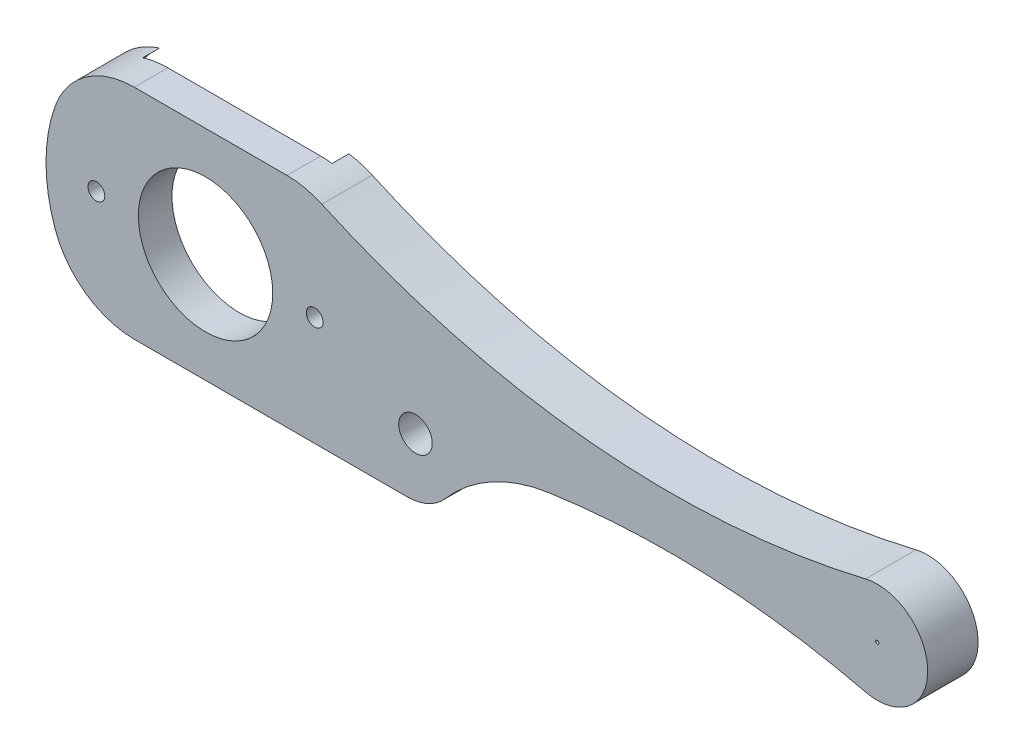
from build123d import *

# Parameters (mm, degrees)
SKIZZE1_W                       = 70
SKIZZE1_H                       = 30
SKIZZE1_R                       = 4
SKIZZE1_R_2                     = 0.1
LINEAR_AUSTRAGEN1_DEPTH         = 3
F_1_0_1_DIAMETER_HOLE1_D        = 1
F_2_0_2_DIAMETER_HOLE1_D        = 2
SKIZZE7_R                       = 8.5
SCHNITT_LINEAR_AUSTRAGEN1_DEPTH = 1
SKIZZE8_OUTSIDE_W               = 87.244
SKIZZE8_OUTSIDE_H               = 47.244
SCHNITT_LINEAR_AUSTRAGEN2_DEPTH = 58.087651905
SCHNITT_LINEAR_AUSTRAGEN3_DEPTH = 1.2


with BuildPart() as part:
    # Skizze1 → Linear austragen1 (new body)
    with BuildSketch(Plane.XY):
        with Locations((20, 0)):
            Rectangle(SKIZZE1_W, SKIZZE1_H)
        Circle(SKIZZE1_R, mode=Mode.SUBTRACT)
        with Locations((40, 0)):
            Circle(SKIZZE1_R_2, mode=Mode.SUBTRACT)
    extrude(amount=LINEAR_AUSTRAGEN1_DEPTH)

    # Ø1.0 (1) Diameter Hole1 (through all)
    with Locations(Plane(origin=(0, 0, 0), x_dir=(-1, 0, 0), z_dir=(0, 0, -1))):
        with Locations((6.5, 0), (-6.5, 0)):
            Hole(F_1_0_1_DIAMETER_HOLE1_D / 2)

    # Ø2.0 (2) Diameter Hole1 (through all)
    with Locations(Plane(origin=(0, 0, 0), x_dir=(1, 0, 0), z_dir=(0, 0, -1))):
        with Locations((12.5, 3)):
            Hole(F_2_0_2_DIAMETER_HOLE1_D / 2)

    # Skizze7 → Schnitt-Linear austragen1 (cut)
    with BuildSketch(Plane.XY):
        Circle(SKIZZE7_R)
    extrude(amount=SCHNITT_LINEAR_AUSTRAGEN1_DEPTH, mode=Mode.SUBTRACT)

    # Skizze8 outside → Schnitt-Linear austragen2 (cut, through all)
    with BuildSketch(Plane.XY):
        with Locations((20, 0)):
            Rectangle(SKIZZE8_OUTSIDE_W, SKIZZE8_OUTSIDE_H)
        with BuildLine():
            Line((-4.242640687, 6.5), (4.850693198, 6.5))
            ThreePointArc((4.850693198, 6.5), (5.911913676, 6.386083411), (6.924777907, 6.049524439))
            ThreePointArc((6.924777907, 6.049524439), (22.851496839, 1.777066749), (39.30182783, 2.917628424))
            ThreePointArc((39.30182783, 2.917628424), (43, 0), (39.30182783, -2.917628424))
            ThreePointArc((39.30182783, -2.917628424), (29.897933333, -1.594625688), (20.413511825, -2.073495804))
            ThreePointArc((20.413511825, -2.073495804), (17.039126957, -3.208684673), (14.276292568, -5.454096248))
            ThreePointArc((14.276292568, -5.454096248), (13.252539671, -6.226012541), (12, -6.5))
            Line((12, -6.5), (-4.242640687, -6.5))
            ThreePointArc((-4.242640687, -6.5), (-7.129392033, -5.582482905), (-8.956685895, -3.166666667))
            ThreePointArc((-8.956685895, -3.166666667), (-9.5, 0), (-8.956685895, 3.166666667))
            ThreePointArc((-8.956685895, 3.166666667), (-7.129392033, 5.582482905), (-4.242640687, 6.5))
        make_face(mode=Mode.SUBTRACT)
    extrude(amount=SCHNITT_LINEAR_AUSTRAGEN2_DEPTH, mode=Mode.SUBTRACT)

    # Skizze10 → Schnitt-Linear austragen3 (cut)
    with BuildSketch(Plane.XY):
        with BuildLine():
            ThreePointArc((36.376629725, 1.49720748), (23.054109204, 0.954513618), (10.049282761, 3.89705654))
            ThreePointArc((10.049282761, 3.89705654), (9.397134344, 3.759216075), (9.240224203, 3.111391438))
            ThreePointArc((9.240224203, 3.111391438), (9.689735111, 1.082373999), (9.699012563, -0.995818907))
            ThreePointArc((9.699012563, -0.995818907), (10.068812364, -1.631628436), (10.787531238, -1.47526722))
            ThreePointArc((10.787531238, -1.47526722), (13.150598424, -0.801345638), (14.766431088, -2.652653724))
            ThreePointArc((14.766431088, -2.652653724), (15.136326342, -3.131711101), (15.73868827, -3.072731627))
            ThreePointArc((15.73868827, -3.072731627), (17.915226797, -1.915501516), (20.297478014, -1.281955435))
            ThreePointArc((20.297478014, -1.281955435), (28.345625064, -0.749320212), (36.376629725, -1.49720748))
            ThreePointArc((36.376629725, -1.49720748), (36.94164037, -1.30691696), (37.090043464, -0.729488148))
            ThreePointArc((37.090043464, -0.729488148), (37, 0), (37.090043464, 0.729488148))
            ThreePointArc((37.090043464, 0.729488148), (36.94164037, 1.30691696), (36.376629725, 1.49720748))
        make_face()
    extrude(amount=SCHNITT_LINEAR_AUSTRAGEN3_DEPTH, mode=Mode.SUBTRACT)


solid = part.part
